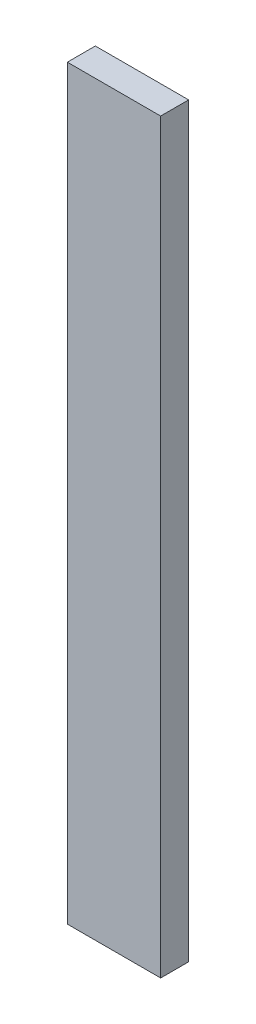
from build123d import *

# Parameters (mm, degrees)
SKETCH1_W           = 10
SKETCH1_H           = 80
BOSS_EXTRUDE1_DEPTH = 3


with BuildPart() as part:
    # Sketch1 → Boss-Extrude1 (new body)
    with BuildSketch(Plane.XY):
        Rectangle(SKETCH1_W, SKETCH1_H)
    extrude(amount=BOSS_EXTRUDE1_DEPTH)


solid = part.part
